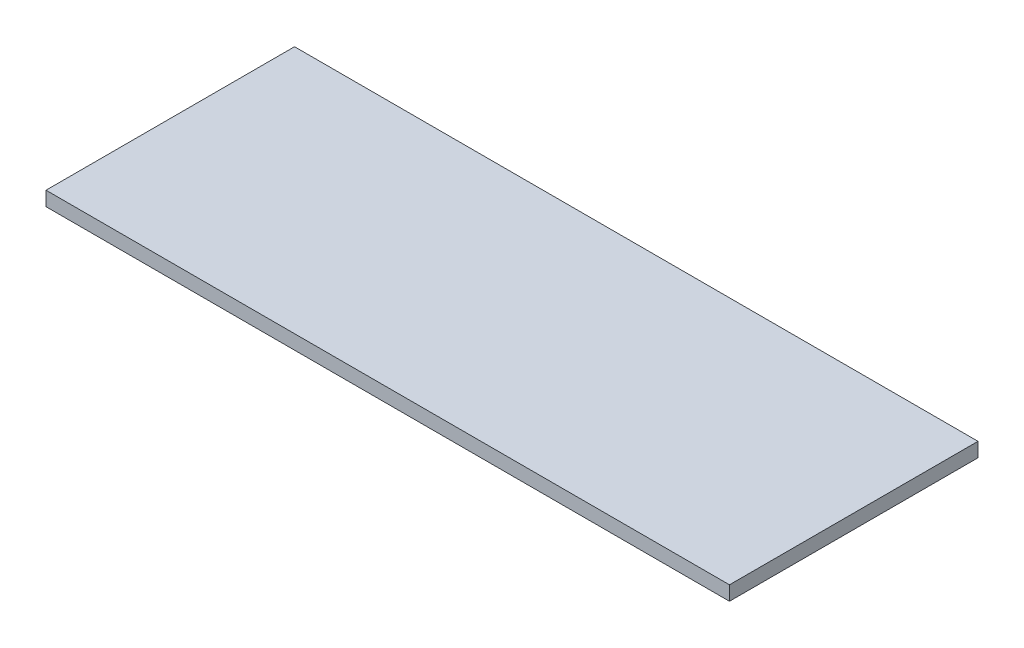
from build123d import *

# Parameters (mm, degrees)
SKETCH1_W           = 55
SKETCH1_H           = 20
BOSS_EXTRUDE1_DEPTH = 1.15


with BuildPart() as part:
    # Sketch1 → Boss-Extrude1 (new body)
    with BuildSketch(Plane(origin=(0, 0, 0), x_dir=(1, 0, 0), z_dir=(0, 1, 0))):
        with Locations((-27.5, 10)):
            Rectangle(SKETCH1_W, SKETCH1_H)
    extrude(amount=BOSS_EXTRUDE1_DEPTH)


solid = part.part
